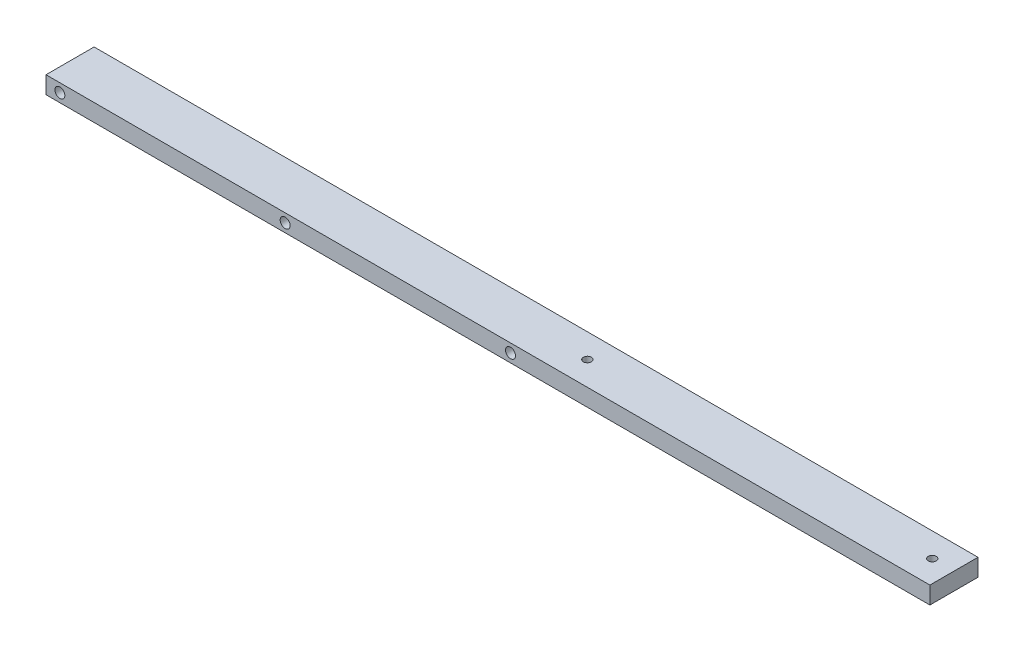
from build123d import *

# Parameters (mm, degrees)
SKETCH1_W                                           = 17.6276
SKETCH1_H                                           = 6.35
BOSS_EXTRUDE1_DEPTH                                 = 323.85
F_6_CLEARANCE_HOLE1_D                               = 3.6576
CBORE_FOR_4_BINDING_HEAD_MACHINE_SCREW2_D           = 2.9464
CBORE_FOR_4_BINDING_HEAD_MACHINE_SCREW2_CBORE_D     = 4.8006
CBORE_FOR_4_BINDING_HEAD_MACHINE_SCREW2_CBORE_DEPTH = 2.8448


with BuildPart() as part:
    # Sketch1 → Boss-Extrude1 (new body)
    with BuildSketch(Plane(origin=(0, 0, 0), x_dir=(0, 0, -1), z_dir=(1, 0, 0))):
        with Locations((8.8138, 3.175)):
            Rectangle(SKETCH1_W, SKETCH1_H)
    extrude(amount=BOSS_EXTRUDE1_DEPTH)

    # #6 Clearance Hole1 (through all)
    with Locations(Plane.XY):
        with Locations((5.08, 3.175), (87.63, 3.175), (170.18, 3.175)):
            Hole(F_6_CLEARANCE_HOLE1_D / 2)

    # CBORE for #4 Binding Head Machine Screw2 (through all)
    with Locations(Plane(origin=(0, 0, 0), x_dir=(-1, 0, 0), z_dir=(0, -1, 0))):
        with Locations((-315.9125, 8.8138), (-189.5475, 8.8138)):
            CounterBoreHole(CBORE_FOR_4_BINDING_HEAD_MACHINE_SCREW2_D / 2, CBORE_FOR_4_BINDING_HEAD_MACHINE_SCREW2_CBORE_D / 2, CBORE_FOR_4_BINDING_HEAD_MACHINE_SCREW2_CBORE_DEPTH)


solid = part.part
